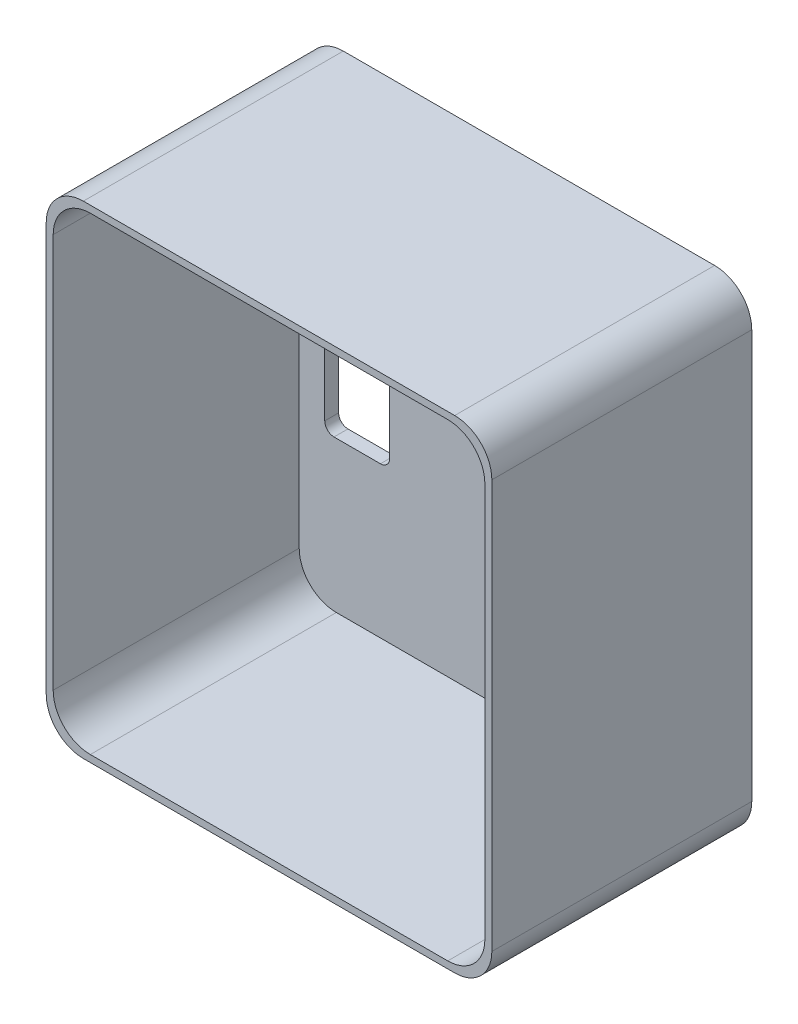
from build123d import *

# Parameters (mm, degrees)
BOSS_EXTRUDE1_DEPTH = 28
CUT_EXTRUDE1_DEPTH  = 26.5
CUT_EXTRUDE2_DEPTH  = 2.5


with BuildPart() as part:
    # Sketch1 → Boss-Extrude1 (new body)
    with BuildSketch(Plane.XY):
        with BuildLine():
            Line((-20, 26), (20, 26))
            ThreePointArc((20, 26), (22.828427125, 24.828427125), (24, 22))
            Line((24, 22), (24, -22))
            ThreePointArc((24, -22), (22.828427125, -24.828427125), (20, -26))
            Line((20, -26), (-20, -26))
            ThreePointArc((-20, -26), (-22.828427125, -24.828427125), (-24, -22))
            Line((-24, -22), (-24, 22))
            ThreePointArc((-24, 22), (-22.828427125, 24.828427125), (-20, 26))
        make_face()
    extrude(amount=BOSS_EXTRUDE1_DEPTH)

    # Sketch2 → Cut-Extrude1 (cut)
    with BuildSketch(Plane.XY.offset(28)):
        with BuildLine():
            Line((-19.25, 25.25), (19.25, 25.25))
            ThreePointArc((19.25, 25.25), (22.078427125, 24.078427125), (23.25, 21.25))
            Line((23.25, 21.25), (23.25, -21.25))
            ThreePointArc((23.25, -21.25), (22.078427125, -24.078427125), (19.25, -25.25))
            Line((19.25, -25.25), (-19.25, -25.25))
            ThreePointArc((-19.25, -25.25), (-22.078427125, -24.078427125), (-23.25, -21.25))
            Line((-23.25, -21.25), (-23.25, 21.25))
            ThreePointArc((-23.25, 21.25), (-22.078427125, 24.078427125), (-19.25, 25.25))
        make_face()
    extrude(amount=-CUT_EXTRUDE1_DEPTH, mode=Mode.SUBTRACT)

    # Sketch3 → Cut-Extrude2 (cut, through all)
    with BuildSketch(Plane.XY.offset(1.5)):
        with BuildLine():
            Line((-19.5, 9), (-14.5, 9))
            ThreePointArc((-14.5, 9), (-13.792893219, 8.707106781), (-13.5, 8))
            Line((-13.5, 8), (-13.5, -8))
            ThreePointArc((-13.5, -8), (-13.792893219, -8.707106781), (-14.5, -9))
            Line((-14.5, -9), (-19.5, -9))
            ThreePointArc((-19.5, -9), (-20.207106781, -8.707106781), (-20.5, -8))
            Line((-20.5, -8), (-20.5, 8))
            ThreePointArc((-20.5, 8), (-20.207106781, 8.707106781), (-19.5, 9))
        make_face()
    extrude(amount=-CUT_EXTRUDE2_DEPTH, mode=Mode.SUBTRACT)


solid = part.part
